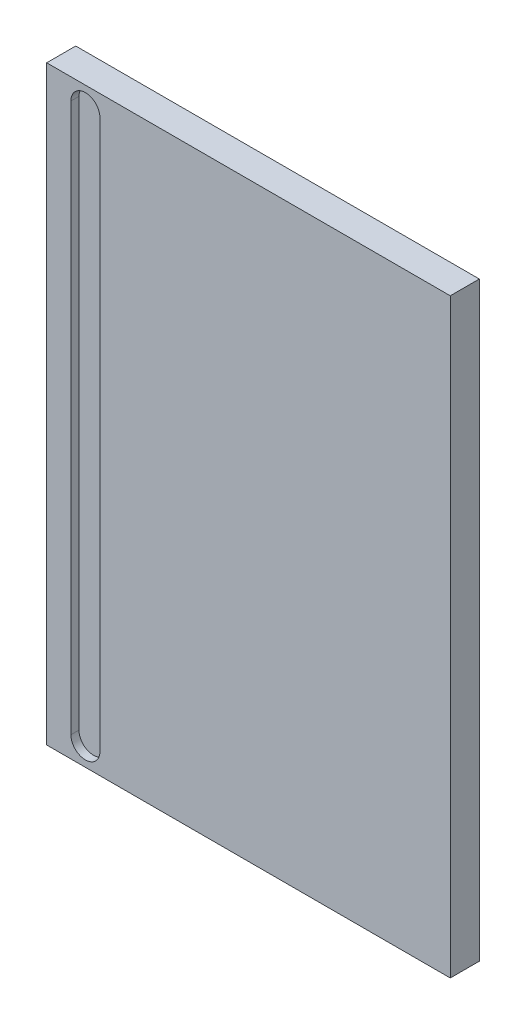
from build123d import *

# Parameters (mm, degrees)
SKETCH_1_W          = 250
SKETCH_1_H          = 366
EXTRUDE_1_DEPTH     = 18
CUT_EXTRUDE_1_DEPTH = 5


with BuildPart() as part:
    # Эскиз1 → Бобышка-Вытянуть1 (new body)
    with BuildSketch(Plane.XY):
        Rectangle(SKETCH_1_W, SKETCH_1_H)
    extrude(amount=EXTRUDE_1_DEPTH)

    # Эскиз2 → Вырез-Вытянуть1 (cut)
    with BuildSketch(Plane.XY.offset(18)):
        with BuildLine():
            Line((-110, 170), (-110, -170))
            ThreePointArc((-110, -170), (-101, -179), (-92, -170))
            Line((-92, -170), (-92, 170))
            ThreePointArc((-92, 170), (-101, 179), (-110, 170))
        make_face()
    extrude(amount=-CUT_EXTRUDE_1_DEPTH, mode=Mode.SUBTRACT)


solid = part.part
